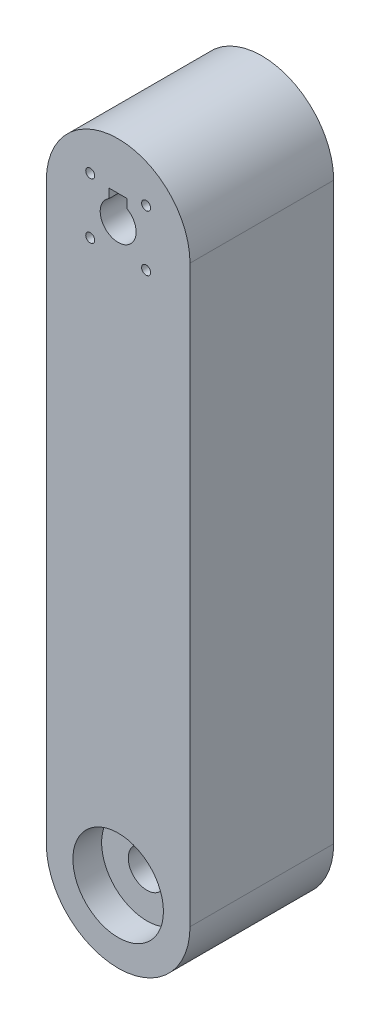
from build123d import *

# Parameters (mm, degrees)
BOSS_EXTRUDE1_DEPTH = 25.4
CUT_EXTRUDE1_REACH  = 71.561
SKETCH2_R           = 3.175
SKETCH2_R_2         = 0.79375
SKETCH3_W           = 3.175
SKETCH3_H           = 1.5875
CUT_EXTRUDE2_DEPTH  = 70.560764803
SKETCH4_R           = 8.001
CUT_EXTRUDE3_DEPTH  = 5.08
SKETCH5_R           = 3.302
CUT_EXTRUDE4_DEPTH  = 68.870777217


with BuildPart() as part:
    # Sketch1 → Boss-Extrude1 (new body)
    with BuildSketch(Plane.XY):
        with BuildLine():
            Line((12.7, 50.8), (12.7, -50.8))
            ThreePointArc((12.7, -50.8), (0, -63.5), (-12.7, -50.8))
            Line((-12.7, -50.8), (-12.7, 50.8))
            ThreePointArc((-12.7, 50.8), (0, 63.5), (12.7, 50.8))
        make_face()
    extrude(amount=BOSS_EXTRUDE1_DEPTH)

    # Sketch2 → Cut-Extrude1 (cut, up to next)
    with BuildSketch(Plane.XY.offset(25.4), mode=Mode.PRIVATE) as cut_extrude1_sk1:
        with Locations((0, 50.8)):
            Circle(SKETCH2_R)
    cut_extrude1_tool1 = extrude(cut_extrude1_sk1.sketch, amount=-CUT_EXTRUDE1_REACH, mode=Mode.PRIVATE) & part.part
    # Sketch2 → Cut-Extrude1 (cut, up to next)
    with BuildSketch(Plane.XY.offset(25.4), mode=Mode.PRIVATE) as cut_extrude1_sk2:
        with Locations((-4.939140867, 55.739140867)):
            Circle(SKETCH2_R_2)
    cut_extrude1_tool2 = extrude(cut_extrude1_sk2.sketch, amount=-CUT_EXTRUDE1_REACH, mode=Mode.PRIVATE) & part.part
    # Sketch2 → Cut-Extrude1 (cut, up to next)
    with BuildSketch(Plane.XY.offset(25.4), mode=Mode.PRIVATE) as cut_extrude1_sk3:
        with Locations((-4.939140867, 45.860859133)):
            Circle(SKETCH2_R_2)
    cut_extrude1_tool3 = extrude(cut_extrude1_sk3.sketch, amount=-CUT_EXTRUDE1_REACH, mode=Mode.PRIVATE) & part.part
    # Sketch2 → Cut-Extrude1 (cut, up to next)
    with BuildSketch(Plane.XY.offset(25.4), mode=Mode.PRIVATE) as cut_extrude1_sk4:
        with Locations((4.939140867, 55.739140867)):
            Circle(SKETCH2_R_2)
    cut_extrude1_tool4 = extrude(cut_extrude1_sk4.sketch, amount=-CUT_EXTRUDE1_REACH, mode=Mode.PRIVATE) & part.part
    # Sketch2 → Cut-Extrude1 (cut, up to next)
    with BuildSketch(Plane.XY.offset(25.4), mode=Mode.PRIVATE) as cut_extrude1_sk5:
        with Locations((4.939140867, 45.860859133)):
            Circle(SKETCH2_R_2)
    cut_extrude1_tool5 = extrude(cut_extrude1_sk5.sketch, amount=-CUT_EXTRUDE1_REACH, mode=Mode.PRIVATE) & part.part
    add(cut_extrude1_tool1.solids().sort_by_distance((0, 50.8, 25.4))[0], mode=Mode.SUBTRACT)
    add(cut_extrude1_tool2.solids().sort_by_distance((-4.939141, 55.739141, 25.4))[0], mode=Mode.SUBTRACT)
    add(cut_extrude1_tool3.solids().sort_by_distance((-4.939141, 45.860859, 25.4))[0], mode=Mode.SUBTRACT)
    add(cut_extrude1_tool4.solids().sort_by_distance((4.939141, 55.739141, 25.4))[0], mode=Mode.SUBTRACT)
    add(cut_extrude1_tool5.solids().sort_by_distance((4.939141, 45.860859, 25.4))[0], mode=Mode.SUBTRACT)

    # Sketch3 → Cut-Extrude2 (cut, through all)
    with BuildSketch(Plane.XY.offset(25.4)):
        with Locations((0, 54.343380657)):
            Rectangle(SKETCH3_W, SKETCH3_H)
    extrude(amount=-CUT_EXTRUDE2_DEPTH, mode=Mode.SUBTRACT)

    # Sketch4 → Cut-Extrude3 (cut)
    with BuildSketch(Plane.XY.offset(25.4)):
        with Locations((0, -50.8)):
            Circle(SKETCH4_R)
    cut_extrude3 = extrude(amount=-CUT_EXTRUDE3_DEPTH, mode=Mode.SUBTRACT)

    # Mirror1: Cut-Extrude3 across plane
    add(cut_extrude3.mirror(Plane.XY.offset(12.7)), mode=Mode.SUBTRACT)

    # Sketch5 → Cut-Extrude4 (cut, through all)
    with BuildSketch(Plane.XY.offset(20.32)):
        with Locations((0, -50.8)):
            Circle(SKETCH5_R)
    extrude(amount=-CUT_EXTRUDE4_DEPTH, mode=Mode.SUBTRACT)


solid = part.part
